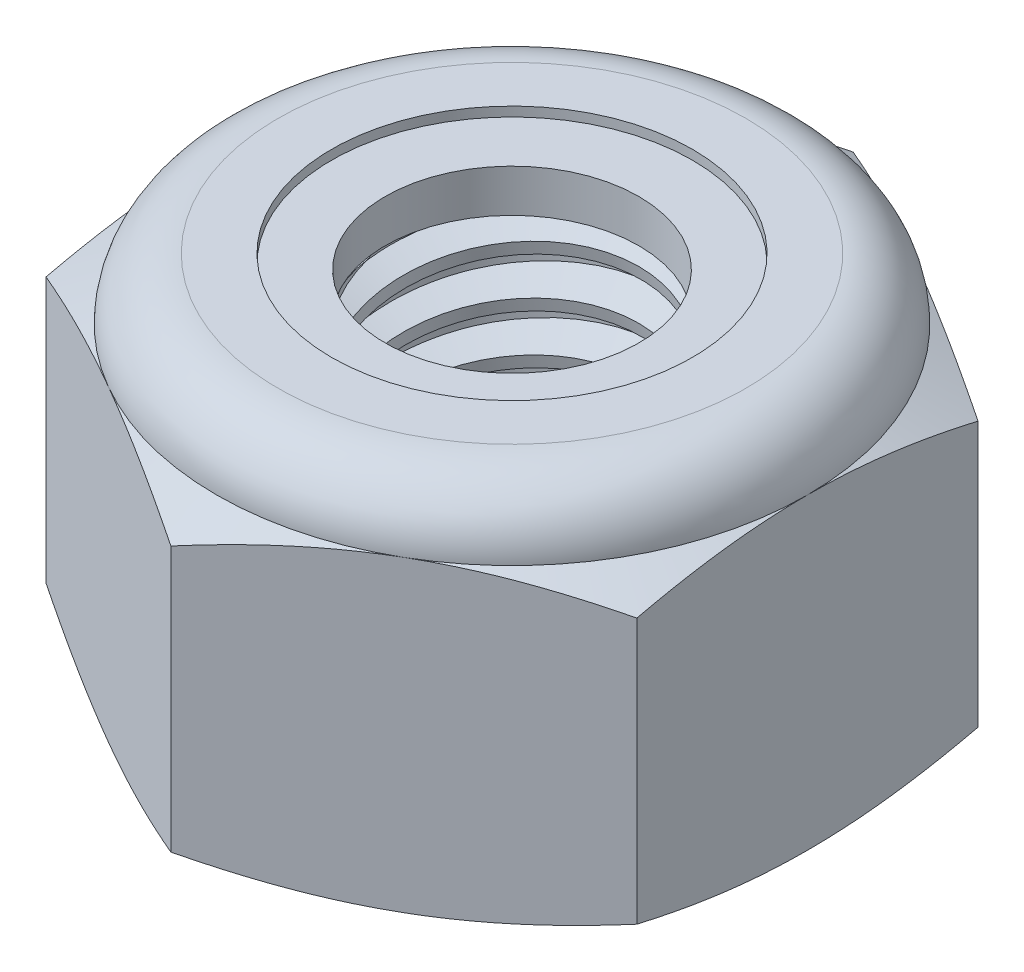
from build123d import *

# Parameters (mm, degrees)
EXTRUDE1_DEPTH      = 5.953125
SKETCH2_W           = 2.413
SKETCH2_H           = 5.953125
LPATTERN1_COUNT     = 8
LPATTERN1_PITCH     = 0.79375
LPATTERN1_COL_COUNT = 2
LPATTERN1_COL_PITCH = 0.79375


with BuildPart() as part:
    # Sketch1 → Extrude1 (new body)
    with BuildSketch(Plane(origin=(0, 0, 0), x_dir=(1, 0, 0), z_dir=(0, 1, 0))):
        Polygon((0, 5.499261314), (-4.7625, 2.749630657), (-4.7625, -2.749630657), (0, -5.499261314), (4.7625, -2.749630657), (4.7625, 2.749630657), align=None)
    extrude(amount=EXTRUDE1_DEPTH)

    # Sketch4 → Cut-Revolve2 (revolve, cut)
    with BuildSketch(Plane(origin=(0, 0, 0), x_dir=(0, 0, -1), z_dir=(1, 0, 0)), mode=Mode.PRIVATE) as cut_revolve2_sk:
        Polygon((0, 5.953125), (2.413, 5.953125), (2.045424837, 5.781721887), (2.045424837, 0.171403113), (2.413, 0), (0, 0), align=None)
    revolve(cut_revolve2_sk.sketch.rotate(Axis((0, 5.953125, 0), (0, 1, 0)), 55.135741266), axis=Axis((0, 5.953125, 0), (0, 1, 0)), mode=Mode.SUBTRACT)  # turned: the seam where the file's is


with BuildPart() as body_2:
    # Sketch2 → Revolve1 (revolve)
    with BuildSketch(Plane(origin=(0, 0, 0), x_dir=(0, 0, -1), z_dir=(1, 0, 0))):
        with Locations((1.2065, 2.9765625)):
            Rectangle(SKETCH2_W, SKETCH2_H)
    revolve(axis=Axis((0, -2.413, 0), (0, 1, 0)))

    # Sketch3 → Cut-Revolve1 (revolve, cut)
    with BuildSketch(Plane(origin=(0, 0, 0), x_dir=(0, 0, -1), z_dir=(1, 0, 0)), mode=Mode.PRIVATE) as cut_revolve1_sk:
        Polygon((2.429102527, 5.855221635), (2.541820218, 5.169898076), (2.077629892, 5.344930502), (2.045424837, 5.540737233), align=None)
    cut_revolve1 = revolve(cut_revolve1_sk.sketch.rotate(Axis((0, 5.953125, 0.139697061), (0, -0.986742581, -0.162293188)), 180), axis=Axis((0, 5.953125, 0.139697061), (0, -0.986742581, -0.162293188)), mode=Mode.SUBTRACT)  # turned: the seam where the file's is

    # LPattern1: Cut-Revolve1 ×8
    with Locations(*[(0, -i * LPATTERN1_PITCH, 0) for i in range(1, LPATTERN1_COUNT)]):
        add(cut_revolve1, mode=Mode.SUBTRACT)

    # LPattern1 col: Cut-Revolve1 ×2
    with Locations(*[(0, i * LPATTERN1_COL_PITCH, 0) for i in range(1, LPATTERN1_COL_COUNT)]):
        add(cut_revolve1, mode=Mode.SUBTRACT)


with BuildPart() as part_1:
    add(part.part)

    # Combine1: cut body 2
    add(body_2.part, mode=Mode.SUBTRACT)

    # Sketch5 → Cut-Revolve3 (revolve, cut)
    with BuildSketch(Plane(origin=(0, 0, 0), x_dir=(0, 0, -1), z_dir=(1, 0, 0)), mode=Mode.PRIVATE) as cut_revolve3_sk:
        with BuildLine():
            Line((0, 0), (4.7625, 0))
            Line((4.7625, 0), (5.499261314, 0.343557443))
            Line((5.499261314, 0.343557443), (5.499261314, 4.617380057))
            Line((5.499261314, 4.617380057), (4.7625, 4.9609375))
            ThreePointArc((4.7625, 4.9609375), (4.471895009, 5.662520009), (3.7703125, 5.953125))
            Line((3.7703125, 5.953125), (3.7703125, 7.223125))
            Line((3.7703125, 7.223125), (6.769261314, 7.223125))
            Line((6.769261314, 7.223125), (6.769261314, -1.27))
            Line((6.769261314, -1.27), (0, -1.27))
            Line((0, -1.27), (0, 0))
        make_face()
    revolve(cut_revolve3_sk.sketch.rotate(Axis((0, 0, 0), (0, 1, 0)), 55.135741266), axis=Axis((0, 0, 0), (0, 1, 0)), mode=Mode.SUBTRACT)  # turned: the seam where the file's is

    # Sketch6 → Cut-Revolve4 (revolve, cut)
    with BuildSketch(Plane(origin=(0, 0, 0), x_dir=(0, 0, -1), z_dir=(1, 0, 0)), mode=Mode.PRIVATE) as cut_revolve4_sk:
        with BuildLine():
            Line((0, 4.9609375), (4.6101, 4.9609375))
            ThreePointArc((4.6101, 4.9609375), (4.364131936, 5.554756936), (3.7703125, 5.800725))
            Line((3.7703125, 5.800725), (2.907868669, 5.800725))
            Line((2.907868669, 5.800725), (2.907868669, 7.223125))
            Line((2.907868669, 7.223125), (0, 7.223125))
            Line((0, 7.223125), (0, 4.9609375))
        make_face()
    revolve(cut_revolve4_sk.sketch.rotate(Axis((0, 7.223125, 0), (0, 1, 0)), 55.135741266), axis=Axis((0, 7.223125, 0), (0, 1, 0)), mode=Mode.SUBTRACT)  # turned: the seam where the file's is


with BuildPart() as body_2_2:
    # Sketch7 → Revolve2 (revolve)
    with BuildSketch(Plane(origin=(0, 0, 0), x_dir=(0, 0, -1), z_dir=(1, 0, 0))):
        with BuildLine():
            Line((2.045424837, 5.0371375), (4.530088408, 5.0371375))
            ThreePointArc((4.530088408, 5.0371375), (4.282601726, 5.527175629), (3.7703125, 5.724525))
            Line((3.7703125, 5.724525), (2.045424837, 5.724525))
            Line((2.045424837, 5.724525), (2.045424837, 5.0371375))
        make_face()
    revolve(axis=Axis((0, 5.0371375, 0), (0, 1, 0)))


solid = Compound([part_1.part, body_2_2.part])
